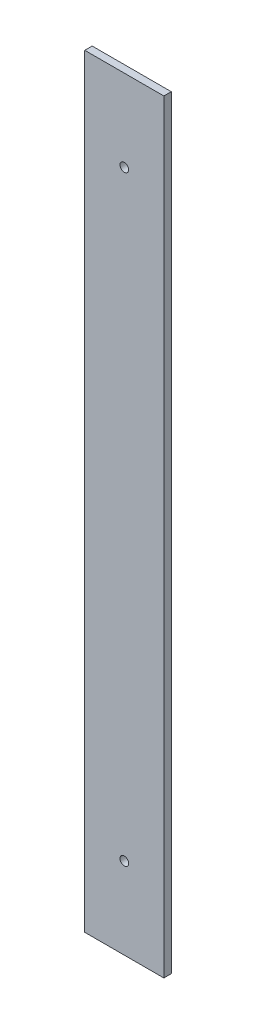
from build123d import *

# Parameters (mm, degrees)
ESQUISSE1_W        = 32
ESQUISSE1_H        = 309
ESQUISSE1_R        = 1.75
BOSS_EXTRU_1_DEPTH = 3


with BuildPart() as part:
    # Esquisse1 → Boss.-Extru.1 (new body)
    with BuildSketch(Plane.XY):
        Rectangle(ESQUISSE1_W, ESQUISSE1_H)
        with Locations((0, 121.5)):
            Circle(ESQUISSE1_R, mode=Mode.SUBTRACT)
        with Locations((0, -121.5)):
            Circle(ESQUISSE1_R, mode=Mode.SUBTRACT)
    extrude(amount=BOSS_EXTRU_1_DEPTH)


solid = part.part
